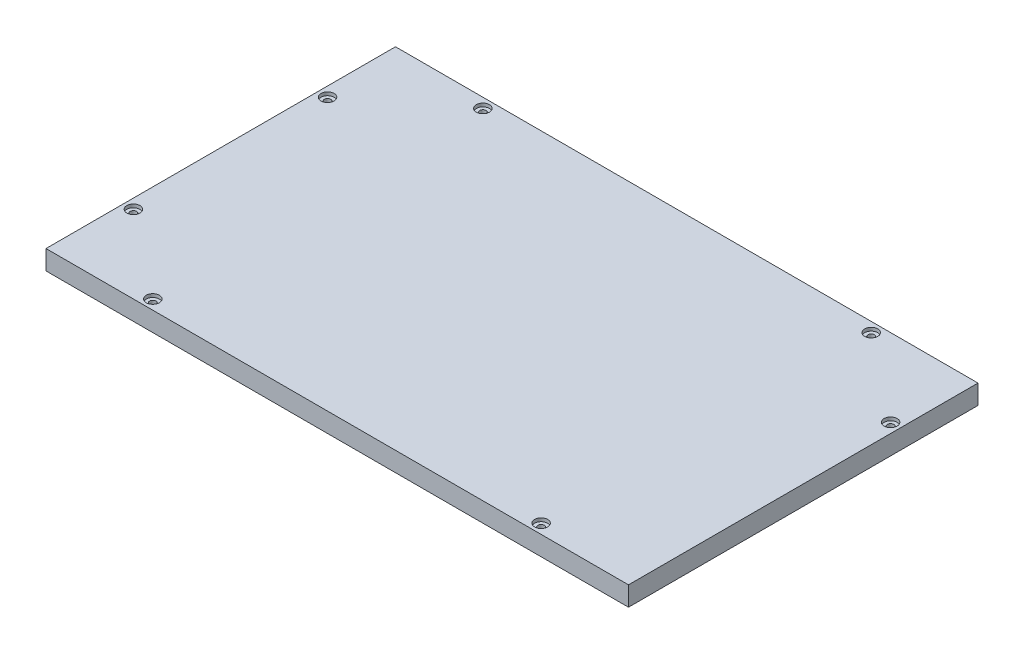
from build123d import *

# Parameters (mm, degrees)
SKETCH1_W                                           = 300
SKETCH1_H                                           = 180
BOSS_EXTRUDE1_DEPTH                                 = 10
CBORE_FOR_4_BINDING_HEAD_MACHINE_SCREW1_D           = 3.2639
CBORE_FOR_4_BINDING_HEAD_MACHINE_SCREW1_DEPTH       = 10
CBORE_FOR_4_BINDING_HEAD_MACHINE_SCREW1_CBORE_D     = 6.74624
CBORE_FOR_4_BINDING_HEAD_MACHINE_SCREW1_CBORE_DEPTH = 1.7272


with BuildPart() as part:
    # Sketch1 → Boss-Extrude1 (new body)
    with BuildSketch(Plane(origin=(0, 0, 0), x_dir=(1, 0, 0), z_dir=(0, 1, 0))):
        with Locations((21.639344262, -12.295081967)):
            Rectangle(SKETCH1_W, SKETCH1_H)
    extrude(amount=BOSS_EXTRUDE1_DEPTH)

    # CBORE for #4 Binding Head Machine Screw1
    with Locations(Plane(origin=(0, 10, 0), x_dir=(1, 0, 0), z_dir=(0, 1, 0))):
        with Locations((-123.360655738, 37.704918033), (-123.360655738, -62.295081967), (-78.360655738, -97.295081967), (121.639344262, -97.295081967), (121.639344262, 72.704918033), (166.639344262, 37.704918033), (-78.360655738, 72.704918033)):
            CounterBoreHole(CBORE_FOR_4_BINDING_HEAD_MACHINE_SCREW1_D / 2, CBORE_FOR_4_BINDING_HEAD_MACHINE_SCREW1_CBORE_D / 2, CBORE_FOR_4_BINDING_HEAD_MACHINE_SCREW1_CBORE_DEPTH, depth=CBORE_FOR_4_BINDING_HEAD_MACHINE_SCREW1_DEPTH)


solid = part.part
